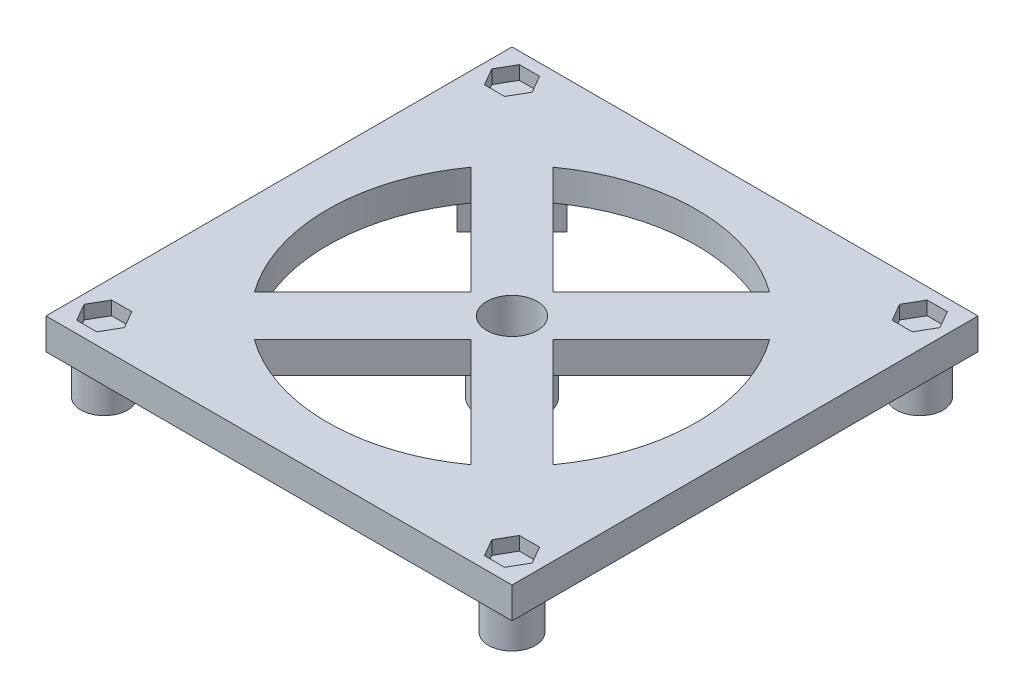
from build123d import *

# Parameters (mm, degrees)
SKETCH2_W            = 120
SKETCH2_H            = 120
BOSS_EXTRUDE1_DEPTH  = 8
CUT_EXTRUDE1_DEPTH   = 3.5
LPATTERN1_COUNT      = 2
LPATTERN1_PITCH      = 105
LPATTERN1_COUNT_DIR2 = 2
LPATTERN1_PITCH_DIR2 = 105
AIR_HOLES_REACH      = 10
HEATER_MOUNTS_DEPTH  = 10
SKETCH14_R           = 3
HEATER_HOLES_DEPTH   = 6.5
CIRPATTERN2_COUNT    = 4
SKETCH11_R           = 8.5
BOSS_EXTRUDE3_DEPTH  = 10
CUT_EXTRUDE9_REACH   = 20
SKETCH16_R           = 6.5
SKETCH17_R           = 6
BOSS_EXTRUDE4_DEPTH  = 10
CUT_EXTRUDE10_DEPTH  = 3.5
LPATTERN4_COUNT      = 2
LPATTERN4_PITCH      = 105
LPATTERN4_COUNT_DIR2 = 2
LPATTERN4_PITCH_DIR2 = 105


with BuildPart() as part:
    # Sketch2 → Boss-Extrude1 (new body)
    with BuildSketch(Plane(origin=(0, 0, 0), x_dir=(1, 0, 0), z_dir=(0, 1, 0))):
        with Locations((-60, -60)):
            Rectangle(SKETCH2_W, SKETCH2_H)
    extrude(amount=BOSS_EXTRUDE1_DEPTH)

    # Sketch3 → Cut-Extrude1 (cut)
    with BuildSketch(Plane(origin=(0, 8, 0), x_dir=(1, 0, 0), z_dir=(0, 1, 0))):
        Polygon((-2.303847577, -112.5), (-4.901923789, -108), (-10.098076211, -108), (-12.696152423, -112.5), (-10.098076211, -117), (-4.901923789, -117), align=None)
    cut_extrude1 = extrude(amount=-CUT_EXTRUDE1_DEPTH, mode=Mode.SUBTRACT)

    # LPattern1: Cut-Extrude1 2 × 2
    with Locations(*[(-i * LPATTERN1_PITCH, 0, -j * LPATTERN1_PITCH_DIR2) for i in range(LPATTERN1_COUNT) for j in range(LPATTERN1_COUNT_DIR2) if (i, j) != (0, 0)]):
        add(cut_extrude1, mode=Mode.SUBTRACT)

    # Sketch8 → air holes (cut, up to next)
    with BuildSketch(Plane.XZ, mode=Mode.PRIVATE) as air_holes_sk1:
        with BuildLine():
            Line((-49.393398282, 60), (-21.530451238, 87.862947045))
            ThreePointArc((-21.530451238, 87.862947045), (-12.5, 60), (-21.530451238, 32.137052955))
            Line((-21.530451238, 32.137052955), (-49.393398282, 60))
        make_face()
    air_holes_tool1 = extrude(air_holes_sk1.sketch, amount=-AIR_HOLES_REACH, mode=Mode.PRIVATE) & part.part
    add(air_holes_tool1.solids().sort_by_distance((-26.860216, 0, 60))[0], mode=Mode.SUBTRACT)
    # Sketch8 → air holes (cut, up to next)
    with BuildSketch(Plane.XZ, mode=Mode.PRIVATE) as air_holes_sk2:
        with BuildLine():
            Line((-32.137052955, 21.530451238), (-60, 49.393398282))
            Line((-60, 49.393398282), (-87.862947045, 21.530451238))
            ThreePointArc((-87.862947045, 21.530451238), (-60, 12.5), (-32.137052955, 21.530451238))
        make_face()
    air_holes_tool2 = extrude(air_holes_sk2.sketch, amount=-AIR_HOLES_REACH, mode=Mode.PRIVATE) & part.part
    add(air_holes_tool2.solids().sort_by_distance((-60, 0, 26.860216))[0], mode=Mode.SUBTRACT)
    # Sketch8 → air holes (cut, up to next)
    with BuildSketch(Plane.XZ, mode=Mode.PRIVATE) as air_holes_sk3:
        with BuildLine():
            Line((-98.469548762, 32.137052955), (-70.606601718, 60))
            Line((-70.606601718, 60), (-98.469548762, 87.862947045))
            ThreePointArc((-98.469548762, 87.862947045), (-107.5, 60), (-98.469548762, 32.137052955))
        make_face()
    air_holes_tool3 = extrude(air_holes_sk3.sketch, amount=-AIR_HOLES_REACH, mode=Mode.PRIVATE) & part.part
    add(air_holes_tool3.solids().sort_by_distance((-93.139784, 0, 60))[0], mode=Mode.SUBTRACT)
    # Sketch8 → air holes (cut, up to next)
    with BuildSketch(Plane.XZ, mode=Mode.PRIVATE) as air_holes_sk4:
        with BuildLine():
            Line((-60, 70.606601718), (-32.137052955, 98.469548762))
            ThreePointArc((-32.137052955, 98.469548762), (-60, 107.5), (-87.862947045, 98.469548762))
            Line((-87.862947045, 98.469548762), (-60, 70.606601718))
        make_face()
    air_holes_tool4 = extrude(air_holes_sk4.sketch, amount=-AIR_HOLES_REACH, mode=Mode.PRIVATE) & part.part
    add(air_holes_tool4.solids().sort_by_distance((-60, 0, 93.139784))[0], mode=Mode.SUBTRACT)

    # Sketch13 → heater_mounts (add)
    with BuildSketch(Plane.XZ):
        Polygon((-16.159379566, 30.30151519), (-11.563185489, 25.705321112), (-25.705321112, 11.563185489), (-30.30151519, 16.159379566), align=None)
    heater_mounts = extrude(amount=HEATER_MOUNTS_DEPTH)

    # Sketch14 → heater_holes (cut)
    with BuildSketch(Plane(origin=(-23.230447378, 0, 23.230447378), x_dir=(0.707106781, 0, 0.707106781), z_dir=(-0.707106781, 0, 0.707106781))):
        with Locations((0, -5)):
            Circle(SKETCH14_R)
    heater_holes = extrude(amount=-HEATER_HOLES_DEPTH, mode=Mode.SUBTRACT)

    # CirPattern2: heater_mounts, heater_holes ×4 about axis
    cirpattern2_axis = Axis((-60, 0, 60), (0, 1, 0))
    for i in range(1, CIRPATTERN2_COUNT):
        add(heater_mounts.rotate(cirpattern2_axis, i * 360 / CIRPATTERN2_COUNT))
        add(heater_holes.rotate(cirpattern2_axis, i * 360 / CIRPATTERN2_COUNT), mode=Mode.SUBTRACT)

    # Sketch11 → Boss-Extrude3 (add)
    with BuildSketch(Plane.XZ):
        with Locations((-60, 60)):
            Circle(SKETCH11_R)
    extrude(amount=BOSS_EXTRUDE3_DEPTH)

    # Sketch16 → Cut-Extrude9 (cut, up to next)
    with BuildSketch(Plane.XZ.offset(10), mode=Mode.PRIVATE) as cut_extrude9_sk1:
        with Locations((-60, 60)):
            Circle(SKETCH16_R)
    cut_extrude9_tool1 = extrude(cut_extrude9_sk1.sketch, amount=-CUT_EXTRUDE9_REACH, mode=Mode.PRIVATE) & part.part
    add(cut_extrude9_tool1.solids().sort_by_distance((-60, -10, 60))[0], mode=Mode.SUBTRACT)

    # Sketch17 → Boss-Extrude4 (add)
    with BuildSketch(Plane.XZ):
        with Locations((-112.5, 112.5)):
            Circle(SKETCH17_R)
    boss_extrude4 = extrude(amount=BOSS_EXTRUDE4_DEPTH)

    # Sketch18 → Cut-Extrude10 (cut)
    with BuildSketch(Plane.XZ.offset(10)):
        Polygon((-117.407477288, 112.5), (-114.953738644, 108.25), (-110.046261356, 108.25), (-107.592522712, 112.5), (-110.046261356, 116.75), (-114.953738644, 116.75), align=None)
    cut_extrude10 = extrude(amount=-CUT_EXTRUDE10_DEPTH, mode=Mode.SUBTRACT)

    # LPattern4: Boss-Extrude4, Cut-Extrude10 2 × 2
    with Locations(*[(i * LPATTERN4_PITCH, 0, -j * LPATTERN4_PITCH_DIR2) for i in range(LPATTERN4_COUNT) for j in range(LPATTERN4_COUNT_DIR2) if (i, j) != (0, 0)]):
        add(boss_extrude4)
        add(cut_extrude10, mode=Mode.SUBTRACT)


solid = part.part
